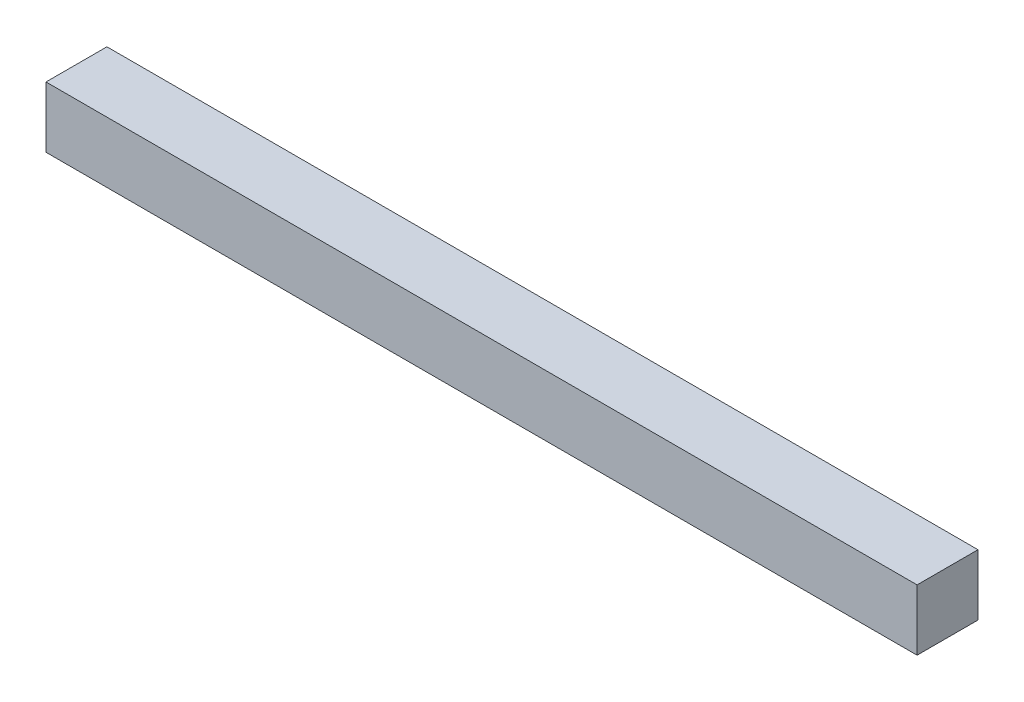
from build123d import *

# Parameters (mm, degrees)
ESQUISSE1_W        = 143
ESQUISSE1_H        = 10
BOSS_EXTRU_1_DEPTH = 10


with BuildPart() as part:
    # Esquisse1 → Boss.-Extru.1 (new body)
    with BuildSketch(Plane.XY):
        with Locations((66.116747734, -1.800947867)):
            Rectangle(ESQUISSE1_W, ESQUISSE1_H)
    extrude(amount=BOSS_EXTRU_1_DEPTH)


solid = part.part
